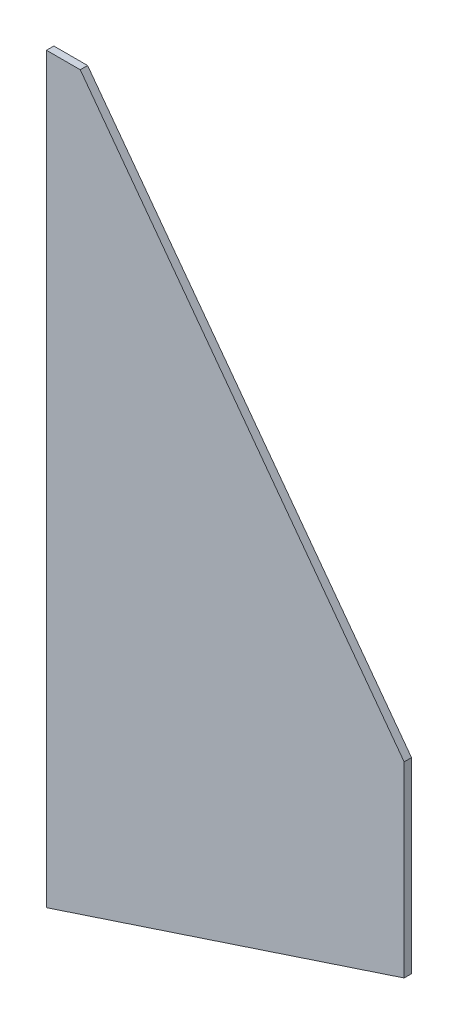
from build123d import *

# Parameters (mm, degrees)
BOSS_EXTRUDE1_DEPTH = 2.9972


with BuildPart() as part:
    # Sketch1 → Boss-Extrude1 (new body)
    with BuildSketch(Plane.XY):
        Polygon((-65.146788831, 198.869144852), (-65.146788831, -103.390855148), (80.444415358, -55.387958115), (80.444415358, 20.812041885), (-51.405388831, 198.869144852), align=None)
    extrude(amount=BOSS_EXTRUDE1_DEPTH)


solid = part.part
